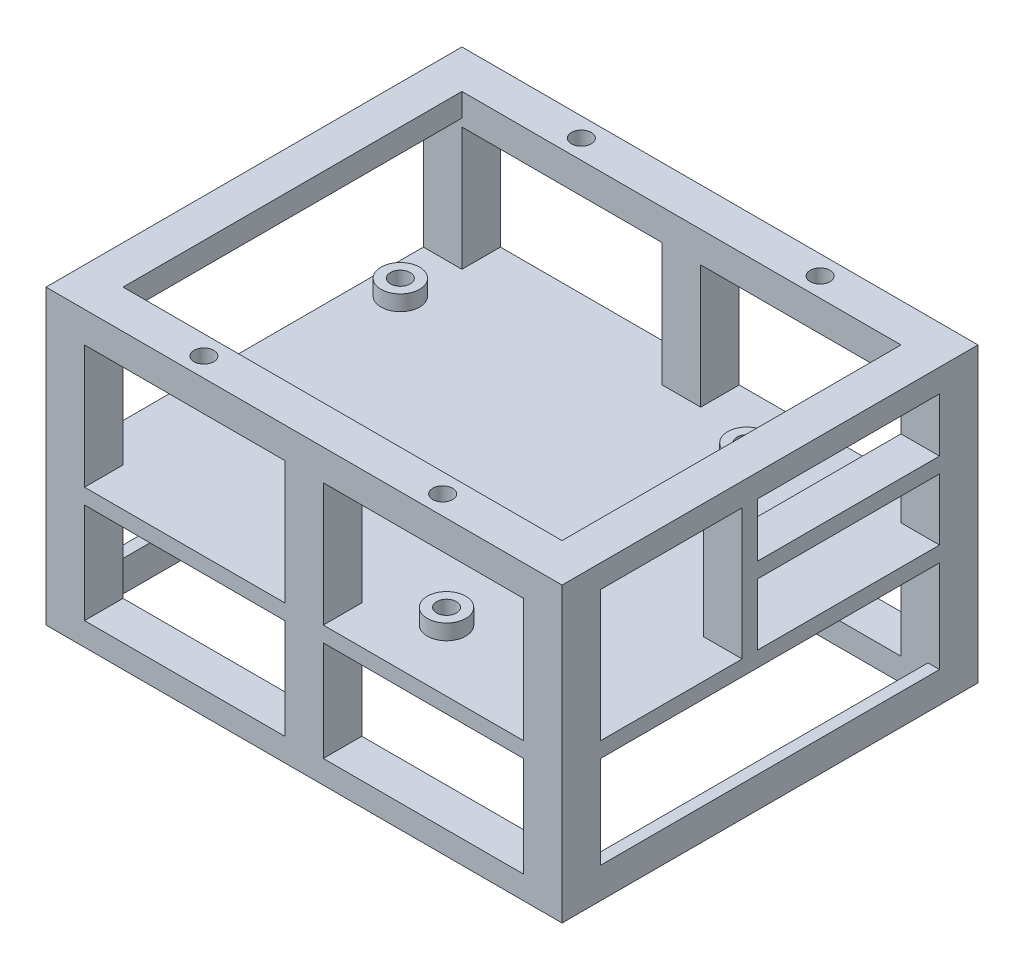
from build123d import *

# Parameters (mm, degrees)
SKETCH1_W                        = 85.09
SKETCH1_H                        = 68.58
BOSS_EXTRUDE1_DEPTH              = 48.26
SKETCH2_W                        = 72.39
SKETCH2_H                        = 55.88
CUT_EXTRUDE1_DEPTH               = 25.4
SKETCH4_W                        = 55.88
SKETCH4_H                        = 21.59
SKETCH4_H_2                      = 15.24
CUT_EXTRUDE2_DEPTH               = 120.467786872
SKETCH5_W                        = 81.28
SKETCH5_H                        = 55.88
CUT_EXTRUDE4_DEPTH               = 20.32
F_30_0_1285_DIAMETER_HOLE1_D     = 3.2639
F_30_0_1285_DIAMETER_HOLE1_DEPTH = 12.7
F_30_0_1285_DIAMETER_HOLE1_TIP   = 0.980574487
SKETCH9_W                        = 33.02
SKETCH9_H                        = 16.51
SKETCH9_H_2                      = 20.32
CUT_EXTRUDE5_DEPTH               = 120.467786872
SKETCH10_R                       = 3.175
SKETCH10_R_2                     = 1.63195
BOSS_EXTRUDE2_DEPTH              = 2.54
CUT_EXTRUDE6_REACH               = 114.199
SKETCH10_3_R                     = 1.63195
SKETCH12_W                       = 6.35
SKETCH12_H                       = 2.54
BOSS_EXTRUDE3_DEPTH              = 22.606
SKETCH13_W                       = 6.35
SKETCH13_H                       = 2.54
BOSS_EXTRUDE4_DEPTH              = 33.782


with BuildPart() as part:
    # Sketch1 → Boss-Extrude1 (new body)
    with BuildSketch(Plane(origin=(0, 0, 0), x_dir=(1, 0, 0), z_dir=(0, 1, 0))):
        with Locations((42.545, 34.29)):
            Rectangle(SKETCH1_W, SKETCH1_H)
    extrude(amount=BOSS_EXTRUDE1_DEPTH)

    # Sketch2 → Cut-Extrude1 (cut)
    with BuildSketch(Plane(origin=(0, 48.26, 0), x_dir=(1, 0, 0), z_dir=(0, 1, 0))):
        with Locations((42.545, 34.29)):
            Rectangle(SKETCH2_W, SKETCH2_H)
    extrude(amount=-CUT_EXTRUDE1_DEPTH, mode=Mode.SUBTRACT)

    # Sketch4 → Cut-Extrude2 (cut, through all)
    with BuildSketch(Plane.ZY):
        with Locations((-34.29, 33.655)):
            Rectangle(SKETCH4_W, SKETCH4_H)
        with Locations((-34.29, 12.7)):
            Rectangle(SKETCH4_W, SKETCH4_H_2)
    extrude(amount=-CUT_EXTRUDE2_DEPTH, mode=Mode.SUBTRACT)

    # Sketch5 → Cut-Extrude4 (cut)
    with BuildSketch(Plane(origin=(0, 0, 0), x_dir=(-1, 0, 0), z_dir=(0, -1, 0))):
        with Locations((-42.545, 34.29)):
            Rectangle(SKETCH5_W, SKETCH5_H)
    extrude(amount=-CUT_EXTRUDE4_DEPTH, mode=Mode.SUBTRACT)

    # 30 _0.1285_ Diameter Hole1
    with Locations(Plane(origin=(22.86, 48.26, -3.175), x_dir=(0, 0, 1), z_dir=(0, 1, 0))):
        with Locations((0, 0), (-62.23, 0), (-62.23, 39.37), (0, 39.37)):
            Hole(F_30_0_1285_DIAMETER_HOLE1_D / 2, depth=F_30_0_1285_DIAMETER_HOLE1_DEPTH)
            with Locations((0, 0, -(F_30_0_1285_DIAMETER_HOLE1_DEPTH + F_30_0_1285_DIAMETER_HOLE1_TIP / 2))):  # 118° drill point
                Cone(0, F_30_0_1285_DIAMETER_HOLE1_D / 2, F_30_0_1285_DIAMETER_HOLE1_TIP, mode=Mode.SUBTRACT)

    # Sketch9 → Cut-Extrude5 (cut, through all)
    with BuildSketch(Plane.XY):
        with Locations((22.86, 12.065)):
            Rectangle(SKETCH9_W, SKETCH9_H)
        with Locations((22.86, 33.02)):
            Rectangle(SKETCH9_W, SKETCH9_H_2)
        with Locations((62.23, 33.02)):
            Rectangle(SKETCH9_W, SKETCH9_H_2)
        with Locations((62.23, 12.065)):
            Rectangle(SKETCH9_W, SKETCH9_H)
    extrude(amount=-CUT_EXTRUDE5_DEPTH, mode=Mode.SUBTRACT)

    # Sketch10 → Boss-Extrude2 (add)
    # profile 1 of 4: a face of its own
    with BuildSketch(Plane(origin=(0, 22.86, 0), x_dir=(1, 0, 0), z_dir=(0, 1, 0))):
        with Locations((55.88, 10.16)):
            Circle(SKETCH10_R)
        with Locations((55.88, 10.16)):
            Circle(SKETCH10_R_2, mode=Mode.SUBTRACT)
    # profile 2 of 4: a face of its own
    with BuildSketch(Plane(origin=(0, 22.86, 0), x_dir=(1, 0, 0), z_dir=(0, 1, 0))):
        with Locations((57.15, 58.42)):
            Circle(SKETCH10_R)
        with Locations((57.15, 58.42)):
            Circle(SKETCH10_R_2, mode=Mode.SUBTRACT)
    # profile 3 of 4: a face of its own
    with BuildSketch(Plane(origin=(0, 22.86, 0), x_dir=(1, 0, 0), z_dir=(0, 1, 0))):
        with Locations((5.08, 25.4)):
            Circle(SKETCH10_R)
        with Locations((5.08, 25.4)):
            Circle(SKETCH10_R_2, mode=Mode.SUBTRACT)
    # profile 4 of 4: a face of its own
    with BuildSketch(Plane(origin=(0, 22.86, 0), x_dir=(1, 0, 0), z_dir=(0, 1, 0))):
        with Locations((5.08, 53.34)):
            Circle(SKETCH10_R)
        with Locations((5.08, 53.34)):
            Circle(SKETCH10_R_2, mode=Mode.SUBTRACT)
    extrude(amount=BOSS_EXTRUDE2_DEPTH)

    # Sketch10_3 → Cut-Extrude6 (cut, up to next)
    with BuildSketch(Plane(origin=(0, 22.86, 0), x_dir=(1, 0, 0), z_dir=(0, 1, 0)), mode=Mode.PRIVATE) as cut_extrude6_sk1:
        with Locations((5.08, 53.34)):
            Circle(SKETCH10_3_R)
    cut_extrude6_tool1 = extrude(cut_extrude6_sk1.sketch, amount=-CUT_EXTRUDE6_REACH, mode=Mode.PRIVATE) & part.part
    # Sketch10_3 → Cut-Extrude6 (cut, up to next)
    with BuildSketch(Plane(origin=(0, 22.86, 0), x_dir=(1, 0, 0), z_dir=(0, 1, 0)), mode=Mode.PRIVATE) as cut_extrude6_sk2:
        with Locations((5.08, 25.4)):
            Circle(SKETCH10_3_R)
    cut_extrude6_tool2 = extrude(cut_extrude6_sk2.sketch, amount=-CUT_EXTRUDE6_REACH, mode=Mode.PRIVATE) & part.part
    # Sketch10_3 → Cut-Extrude6 (cut, up to next)
    with BuildSketch(Plane(origin=(0, 22.86, 0), x_dir=(1, 0, 0), z_dir=(0, 1, 0)), mode=Mode.PRIVATE) as cut_extrude6_sk3:
        with Locations((57.15, 58.42)):
            Circle(SKETCH10_3_R)
    cut_extrude6_tool3 = extrude(cut_extrude6_sk3.sketch, amount=-CUT_EXTRUDE6_REACH, mode=Mode.PRIVATE) & part.part
    # Sketch10_3 → Cut-Extrude6 (cut, up to next)
    with BuildSketch(Plane(origin=(0, 22.86, 0), x_dir=(1, 0, 0), z_dir=(0, 1, 0)), mode=Mode.PRIVATE) as cut_extrude6_sk4:
        with Locations((55.88, 10.16)):
            Circle(SKETCH10_3_R)
    cut_extrude6_tool4 = extrude(cut_extrude6_sk4.sketch, amount=-CUT_EXTRUDE6_REACH, mode=Mode.PRIVATE) & part.part
    add(cut_extrude6_tool1.solids().sort_by_distance((5.08, 22.86, -53.34))[0], mode=Mode.SUBTRACT)
    add(cut_extrude6_tool2.solids().sort_by_distance((5.08, 22.86, -25.4))[0], mode=Mode.SUBTRACT)
    add(cut_extrude6_tool3.solids().sort_by_distance((57.15, 22.86, -58.42))[0], mode=Mode.SUBTRACT)
    add(cut_extrude6_tool4.solids().sort_by_distance((55.88, 22.86, -10.16))[0], mode=Mode.SUBTRACT)

    # Sketch12 → Boss-Extrude3 (add)
    with BuildSketch(Plane(origin=(0, 22.86, 0), x_dir=(1, 0, 0), z_dir=(0, 1, 0))):
        with Locations((81.915, 30.96)):
            Rectangle(SKETCH12_W, SKETCH12_H)
    extrude(amount=BOSS_EXTRUDE3_DEPTH)

    # Sketch13 → Boss-Extrude4 (add)
    with BuildSketch(Plane(origin=(0, 0, -32.23), x_dir=(-1, 0, 0), z_dir=(0, 0, -1))):
        with Locations((-81.915, 34.29)):
            Rectangle(SKETCH13_W, SKETCH13_H)
    extrude(amount=BOSS_EXTRUDE4_DEPTH)


solid = part.part
